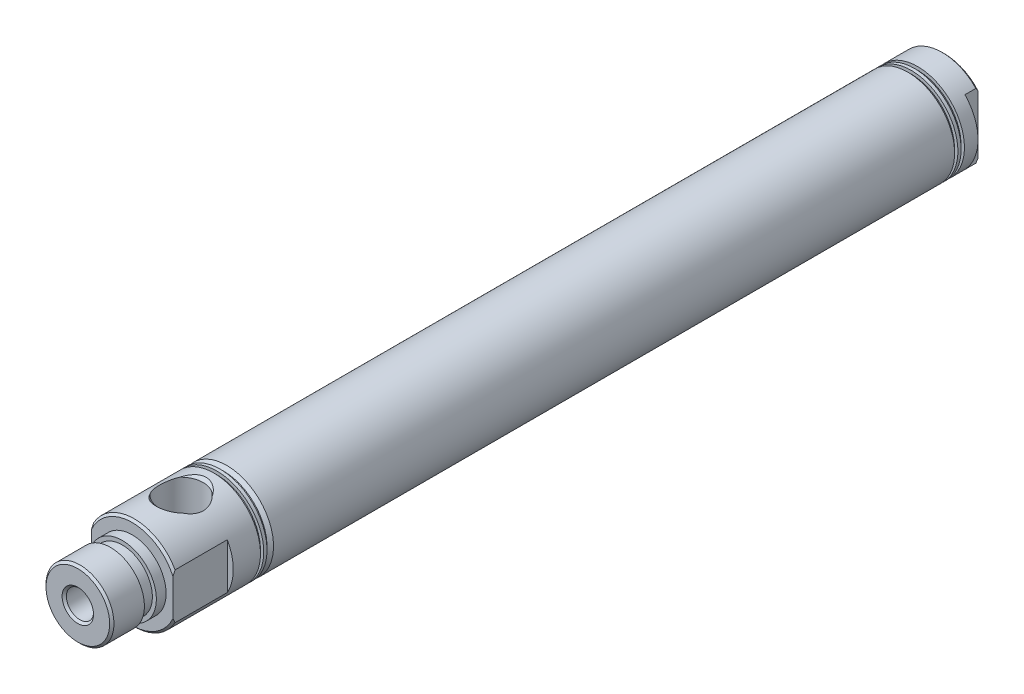
from build123d import *

# Parameters (mm, degrees)
SKETCH1_R           = 10.922
EXTRUDE1_DEPTH      = 94.869
EXTRUDE1_DEPTH_BACK = 94.869
SKETCH3_W           = 0.762
SKETCH3_H           = 0.762
RODHOLE_START       = -173.569
SKETCH8_R           = 3.175
RODHOLE_DEPTH       = 173.569
SKETCH9_R           = 9.525
STROKECHAMBER_DEPTH = 132
CHAMFER1_SIZE       = 0.5
SKETCH4_W           = 1.397
SKETCH4_H           = 12.7
SKETCH4_W_2         = 3.048
SKETCH4_H_2         = 3.048
FLATS_DEPTH         = 11.9220001
FLATS_DEPTH_BACK    = 11.9220001


with BuildPart() as part:
    # Sketch1 → Extrude1 (new body, two sides)
    with BuildSketch(Plane.XY) as extrude1_sk:
        Circle(SKETCH1_R)
    extrude(amount=EXTRUDE1_DEPTH)
    extrude(extrude1_sk.sketch, amount=-EXTRUDE1_DEPTH_BACK)

    # Sketch2 → Nose (revolve)
    with BuildSketch(Plane(origin=(0, 0, 0), x_dir=(0, 0, -1), z_dir=(1, 0, 0))):
        Polygon((-94.869, 7.9248), (-97.155, 7.9248), (-97.155, 7), (-99.955, 7), (-99.955, 7.9375), (-107.569, 7.9375), (-107.569, 0), (-94.869, 0), align=None)
    revolve(axis=Axis((0, 0, 0), (0, 0, 1)))

    # Sketch3 → CoverGrooves (revolve, cut)
    with BuildSketch(Plane(origin=(0, 0, 0), x_dir=(0, 0, -1), z_dir=(1, 0, 0))):
        with Locations((-75.438, 10.541)):
            Rectangle(SKETCH3_W, SKETCH3_H)
        Polygon((-74.295, 10.922), (-74.295, 10.16), (-73.533, 10.16), (-72.771, 10.922), align=None)
        Polygon((88.646, 10.922), (88.646, 10.16), (87.884, 10.922), align=None)
        Polygon((87.122, 10.922), (87.122, 10.16), (86.36, 10.922), align=None)
    revolve(axis=Axis((0, 0, 0), (0, 0, 1)), mode=Mode.SUBTRACT)

    # Sketch7 → FrontPort (revolve, cut)
    with BuildSketch(Plane(origin=(0, 0, 0), x_dir=(0, 0, -1), z_dir=(1, 0, 0))):
        Polygon((-83.439, 10.922), (-77.589, 10.922), (-78.289, 10.222), (-78.289, 0), (-83.439, 0), align=None)
    revolve(axis=Axis((0, 0, 83.439), (0, 1, 0)), mode=Mode.SUBTRACT)

    # Sketch8 → RodHole (cut)
    with BuildSketch(Plane.XY.offset(107.569).offset(RODHOLE_START)):
        Circle(SKETCH8_R)
    extrude(amount=RODHOLE_DEPTH, mode=Mode.SUBTRACT)

    # Sketch9 → StrokeChamber (cut)
    with BuildSketch(Plane.XY.offset(-66)):
        Circle(SKETCH9_R)
    extrude(amount=STROKECHAMBER_DEPTH, mode=Mode.SUBTRACT)

    # Chamfer1
    chamfer1_edges = [part.edges().sort_by_distance(p)[0] for p in [
        (-10.922, 0, -94.869),
        (-3.175, 0, 107.569),
        (0, -7.9375, 107.569),
        (-10.922, 0, 94.869),
    ]]
    chamfer(chamfer1_edges, length=CHAMFER1_SIZE)

    # Sketch4 → Flats (cut, two sides)
    with BuildSketch(Plane(origin=(0, 0, 0), x_dir=(1, 0, 0), z_dir=(0, 1, 0))) as flats_sk:
        with Locations((10.2235, -88.519)):
            Rectangle(SKETCH4_W, SKETCH4_H)
        with Locations((9.398, 93.345)):
            Rectangle(SKETCH4_W_2, SKETCH4_H_2)
        with Locations((-9.398, 93.345)):
            Rectangle(SKETCH4_W_2, SKETCH4_H_2)
        with Locations((-10.2235, -88.519)):
            Rectangle(SKETCH4_W, SKETCH4_H)
    extrude(amount=FLATS_DEPTH, mode=Mode.SUBTRACT)
    extrude(flats_sk.sketch, amount=-FLATS_DEPTH_BACK, mode=Mode.SUBTRACT)

    # Sketch10 → RearStdPort (revolve, cut)
    with BuildSketch(Plane(origin=(0, 0, 0), x_dir=(0, 0, -1), z_dir=(1, 0, 0))):
        Polygon((94.869, 0), (94.869, 5.85), (94.169, 5.15), (0, 5.15), (0, 0), align=None)
    revolve(axis=Axis((0, 0, 0), (0, 0, 1)), mode=Mode.SUBTRACT)


solid = part.part
